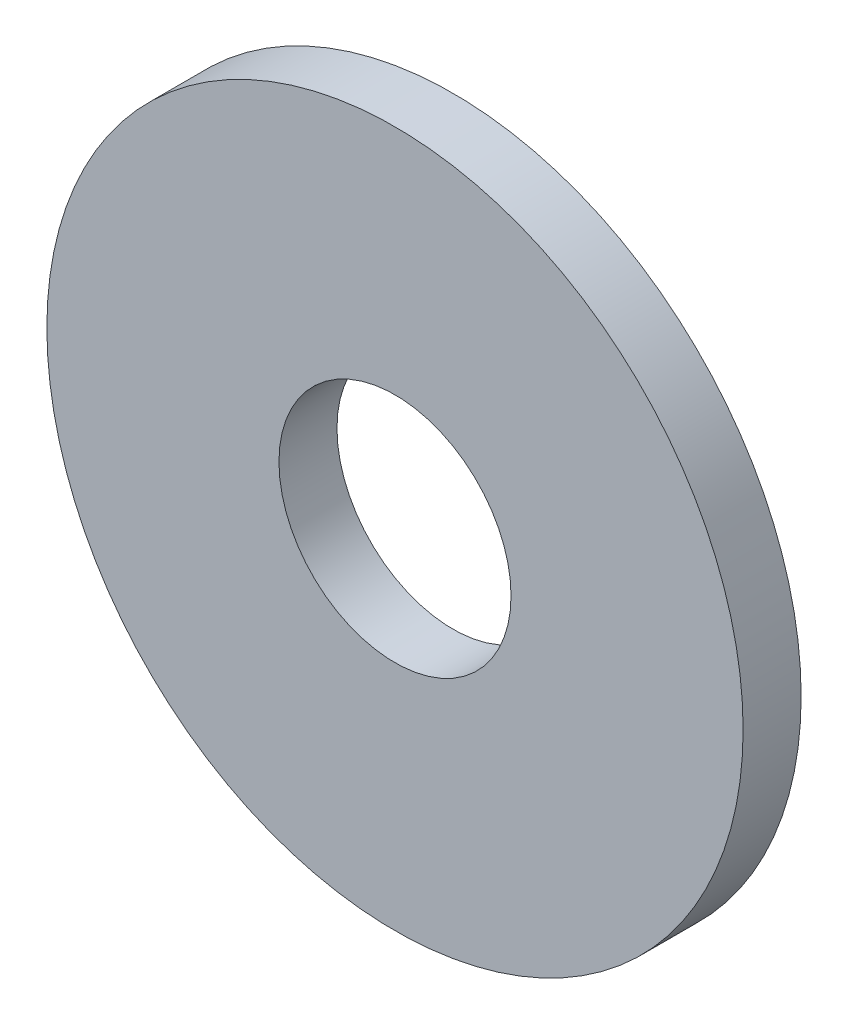
from build123d import *

# Parameters (mm, degrees)
SZKIC1_R                    = 6
SZKIC1_R_2                  = 2
DODANIE_WYCI_GNI_CIE1_DEPTH = 1


with BuildPart() as part:
    # Szkic1 → Dodanie-wyciągnięcie1 (new body)
    with BuildSketch(Plane.XY):
        Circle(SZKIC1_R)
        Circle(SZKIC1_R_2, mode=Mode.SUBTRACT)
    extrude(amount=DODANIE_WYCI_GNI_CIE1_DEPTH)


solid = part.part
